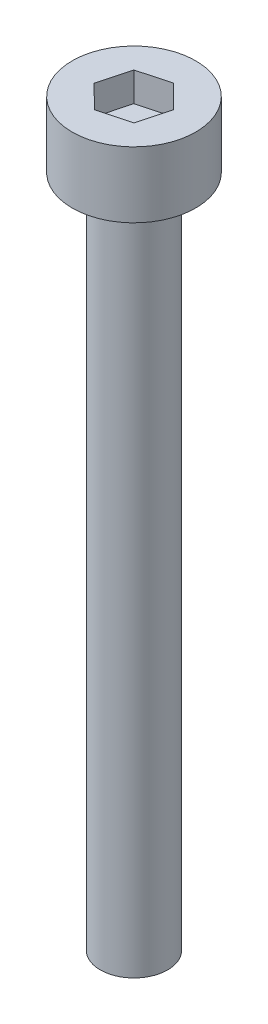
from build123d import *

# Parameters (mm, degrees)
SKETCH_1_R          = 1.5
EXTRUDE_1_DEPTH     = 30
SKETCH_2_R          = 2.75
EXTRUDE_2_DEPTH     = 2.93
CUT_EXTRUDE_1_DEPTH = 1.3


with BuildPart() as part:
    # 草图1 → 凸台-拉伸1 (new body)
    with BuildSketch(Plane(origin=(0, 0, 0), x_dir=(1, 0, 0), z_dir=(0, 1, 0))):
        Circle(SKETCH_1_R)
    extrude(amount=EXTRUDE_1_DEPTH)

    # 草图2 → 凸台-拉伸2 (add)
    with BuildSketch(Plane(origin=(0, 30, 0), x_dir=(1, 0, 0), z_dir=(0, 1, 0))):
        Circle(SKETCH_2_R)
    extrude(amount=EXTRUDE_2_DEPTH)

    # 草图3 → 切除-拉伸1 (cut)
    with BuildSketch(Plane(origin=(0, 32.93, 0), x_dir=(1, 0, 0), z_dir=(0, 1, 0))):
        Polygon((1.024005842, -1.017224346), (1.392945046, 0.378202899), (0.368939204, 1.395427245), (-1.024005842, 1.017224346), (-1.392945046, -0.378202899), (-0.368939204, -1.395427245), align=None)
    extrude(amount=-CUT_EXTRUDE_1_DEPTH, mode=Mode.SUBTRACT)


solid = part.part
